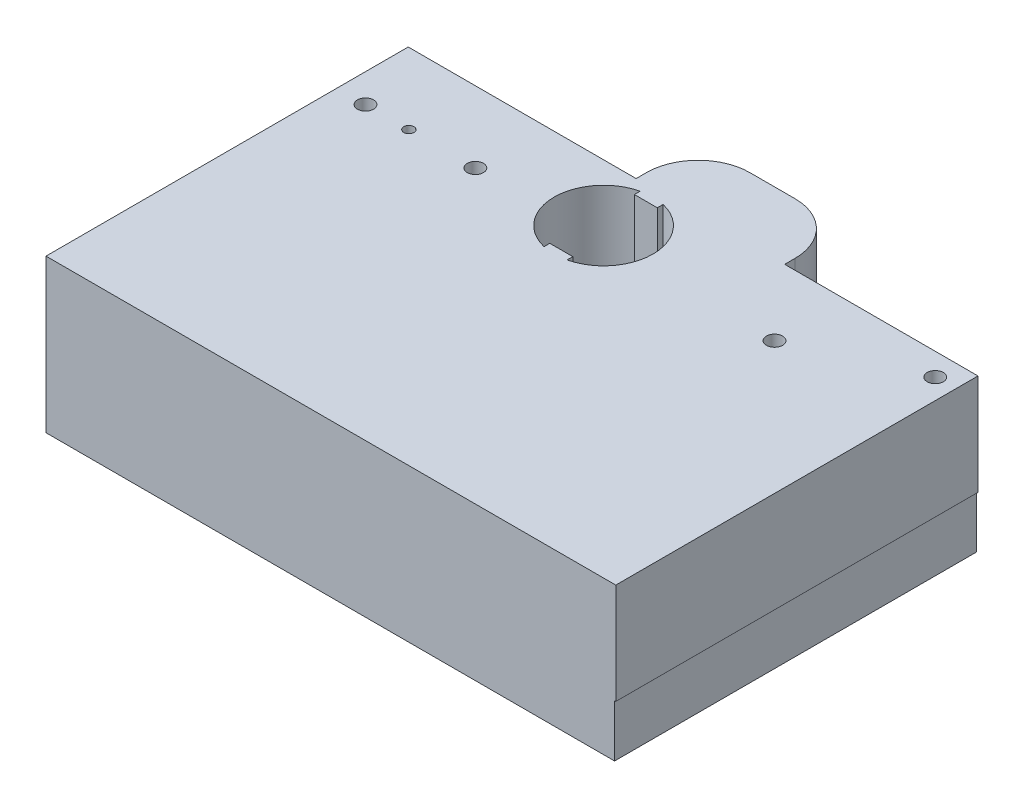
from build123d import *

# Parameters (mm, degrees)
SKETCH1_W           = 279.4
SKETCH1_H           = 177.8
BOSS_EXTRUDE1_DEPTH = 25.654
SKETCH9_R           = 3.96875
CUT_EXTRUDE1_DEPTH  = 38.1
SKETCH9_7_R         = 2.5
SKETCH9_7_R_2       = 3.96875
BOSS_EXTRUDE2_DEPTH = 49.53
SKETCH13_W          = 127.6
SKETCH13_H          = 108.000000046
BOSS_EXTRUDE3_DEPTH = 49.53
SKETCH14_W          = 73
SKETCH14_H          = 49.53
BOSS_EXTRUDE4_DEPTH = 30.48
FILLET1_R           = 25.4
FILLET2_R           = 25.4


with BuildPart() as part:
    # Sketch1 → Boss-Extrude1 (new body)
    with BuildSketch(Plane(origin=(0, 0, 0), x_dir=(1, 0, 0), z_dir=(0, 1, 0))):
        with Locations((139.7, 88.9)):
            Rectangle(SKETCH1_W, SKETCH1_H)
    extrude(amount=BOSS_EXTRUDE1_DEPTH)

    # Sketch9 → Cut-Extrude1 (cut)
    with BuildSketch(Plane(origin=(0, 25.654, 0), x_dir=(1, 0, 0), z_dir=(0, 1, 0))):
        with Locations((215, 143)):
            Circle(SKETCH9_R)
    extrude(amount=-CUT_EXTRUDE1_DEPTH, mode=Mode.SUBTRACT)

    # Sketch9_7 → Boss-Extrude2 (add)
    with BuildSketch(Plane(origin=(0, 25.654, 0), x_dir=(1, 0, 0), z_dir=(0, 1, 0))):
        Polygon((0, 108.000000046), (127.6, 108.000000046), (127.6, 0), (280, 0), (280, 178), (0, 178), align=None)
        with Locations((35.318924397, 143)):
            Circle(SKETCH9_7_R, mode=Mode.SUBTRACT)
        with Locations((14, 143)):
            Circle(SKETCH9_7_R_2, mode=Mode.SUBTRACT)
        with Locations((68, 143)):
            Circle(SKETCH9_7_R_2, mode=Mode.SUBTRACT)
        with Locations((270, 167)):
            Circle(SKETCH9_7_R_2, mode=Mode.SUBTRACT)
        with Locations((215, 143)):
            Circle(SKETCH9_7_R_2, mode=Mode.SUBTRACT)
        with BuildLine():
            Line((129.639279667, 129.22), (129.639279667, 126.383968902))
            ThreePointArc((129.639279667, 126.383968902), (148.28, 150), (129.639279667, 173.616031098))
            Line((129.639279667, 173.616031098), (129.639279667, 170.78))
            Line((129.639279667, 170.78), (118.360720333, 170.78))
            Line((118.360720333, 170.78), (118.360720333, 173.616031098))
            ThreePointArc((118.360720333, 173.616031098), (99.72, 150), (118.360720333, 126.383968902))
            Line((118.360720333, 126.383968902), (118.360720333, 129.22))
            Line((118.360720333, 129.22), (129.639279667, 129.22))
        make_face(mode=Mode.SUBTRACT)
    extrude(amount=BOSS_EXTRUDE2_DEPTH)

    # Sketch13 → Boss-Extrude3 (add)
    with BuildSketch(Plane(origin=(0, 25.654, 0), x_dir=(1, 0, 0), z_dir=(0, 1, 0))):
        with Locations((63.8, 54.000000023)):
            Rectangle(SKETCH13_W, SKETCH13_H)
    extrude(amount=BOSS_EXTRUDE3_DEPTH)

    # Sketch14 → Boss-Extrude4 (add)
    with BuildSketch(Plane(origin=(0, 0, -178), x_dir=(-1, 0, 0), z_dir=(0, 0, -1))):
        with Locations((-148.500000008, 50.419)):
            Rectangle(SKETCH14_W, SKETCH14_H)
    extrude(amount=BOSS_EXTRUDE4_DEPTH)

    # Fillet1
    fillet1_edges = [part.edges().sort_by_distance(p)[0] for p in [
        (185.000000008, 50.419, -208.48),
    ]]
    fillet(fillet1_edges, radius=FILLET1_R)

    # Fillet2
    fillet2_edges = [part.edges().sort_by_distance(p)[0] for p in [
        (112.000000008, 50.419, -208.48),
    ]]
    fillet(fillet2_edges, radius=FILLET2_R)


solid = part.part
